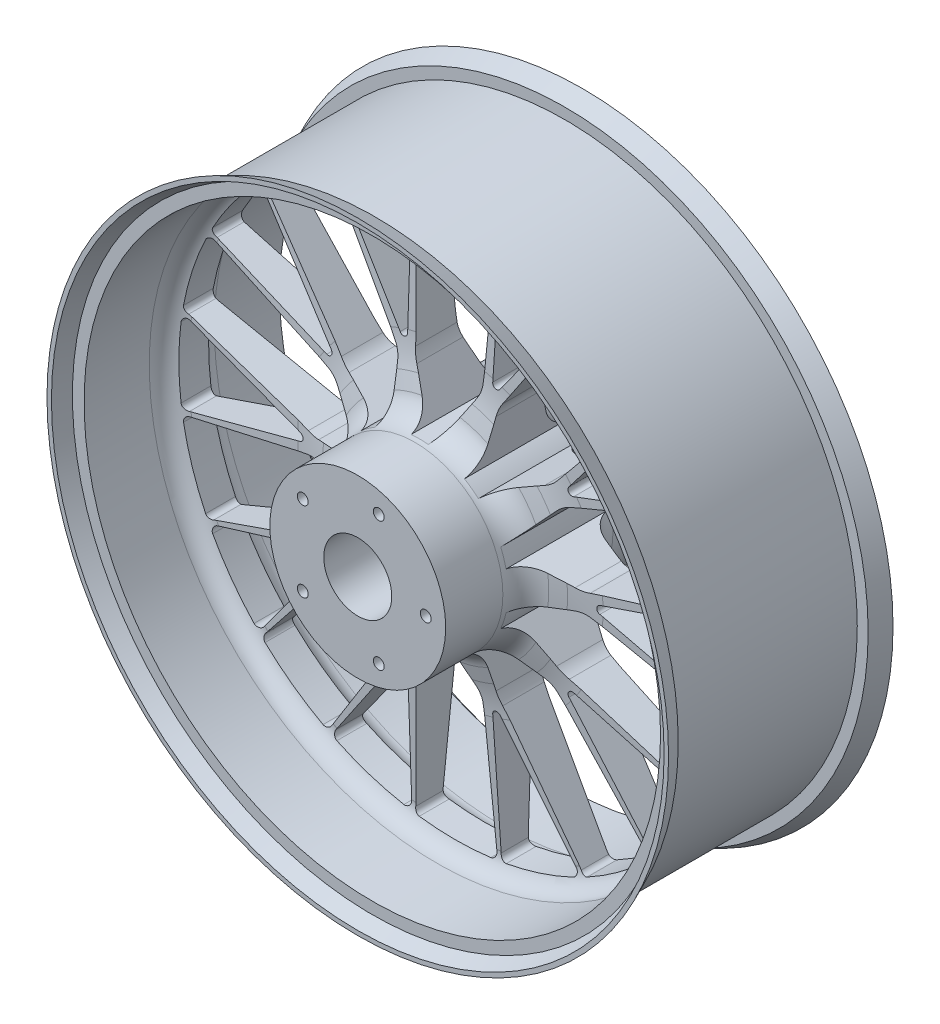
from build123d import *

# Parameters (mm, degrees)
SKETCH1_R           = 228.6
SKETCH1_R_2         = 25
SKETCH1_R_3         = 4
BOSS_EXTRUDE1_DEPTH = 82.55


with BuildPart() as part:
    # Sketch1 → Boss-Extrude1 (new body, symmetric)
    with BuildSketch(Plane.XY):
        Circle(SKETCH1_R)
        Circle(SKETCH1_R_2, mode=Mode.SUBTRACT)
        with Locations((15.45085, 47.552826)):
            Circle(SKETCH1_R_3, mode=Mode.SUBTRACT)
        with Locations((50, 0)):
            Circle(SKETCH1_R_3, mode=Mode.SUBTRACT)
        with Locations((15.45085, -47.552826)):
            Circle(SKETCH1_R_3, mode=Mode.SUBTRACT)
        with Locations((-40.45085, -29.389263)):
            Circle(SKETCH1_R_3, mode=Mode.SUBTRACT)
        with Locations((-40.45085, 29.389263)):
            Circle(SKETCH1_R_3, mode=Mode.SUBTRACT)
        with BuildLine():
            Line((-29.808072, 197.311036), (-24.75602, 100.912126))
            ThreePointArc((-24.75602, 100.912126), (-23.959824, 96.278538), (-22.103937, 91.958845))
            Line((-22.103937, 91.958845), (-6.35921, 64.688179))
            ThreePointArc((-6.35921, 64.688179), (0, 65), (6.35921, 64.688179))
            Line((6.35921, 64.688179), (22.103937, 91.958845))
            ThreePointArc((22.103937, 91.958845), (23.959824, 96.278538), (24.75602, 100.912126))
            Line((24.75602, 100.912126), (29.808072, 197.311036))
            ThreePointArc((29.808072, 197.311036), (28.887709, 200.079593), (26.331899, 201.486652))
            ThreePointArc((26.331899, 201.486652), (0, 203.2), (-26.331899, 201.486652))
            ThreePointArc((-26.331899, 201.486652), (-28.887709, 200.079593), (-29.808072, 197.311036))
        make_face(mode=Mode.SUBTRACT)
        with BuildLine():
            Line((91.86128, 177.148727), (39.286619, 96.190848))
            ThreePointArc((39.286619, 96.190848), (37.2072, 91.974204), (36.169592, 87.388636))
            Line((36.169592, 87.388636), (32.878048, 56.071686))
            ThreePointArc((32.878048, 56.071686), (38.206041, 52.586105), (43.167467, 48.595986))
            Line((43.167467, 48.595986), (71.934513, 61.4039))
            ThreePointArc((71.934513, 61.4039), (75.975009, 63.807742), (79.3427, 67.088401))
            Line((79.3427, 67.088401), (140.091754, 142.107236))
            ThreePointArc((140.091754, 142.107236), (140.974482, 144.888022), (139.733836, 147.528624))
            ThreePointArc((139.733836, 147.528624), (119.437963, 164.392253), (97.127929, 178.483628))
            ThreePointArc((97.127929, 178.483628), (94.233187, 178.84756), (91.86128, 177.148727))
        make_face(mode=Mode.SUBTRACT)
        with BuildLine():
            Line((-31.301343, 105.619631), (-32.875918, 195.826934))
            ThreePointArc((-32.875918, 195.826934), (-34.34903, 198.858401), (-37.615776, 199.68799))
            ThreePointArc((-37.615776, 199.68799), (-62.772389, 193.261137), (-86.904095, 183.678846))
            ThreePointArc((-86.904095, 183.678846), (-89.059737, 181.088459), (-88.471019, 177.770281))
            Line((-88.471019, 177.770281), (-36.758343, 103.846544))
            ThreePointArc((-36.758343, 103.846544), (-35.2528, 102.722302), (-33.373835, 102.714104))
            ThreePointArc((-33.373835, 102.714104), (-31.85854, 103.825164), (-31.301343, 105.619631))
        make_face(mode=Mode.SUBTRACT)
        with BuildLine():
            Line((36.758343, 103.846544), (88.507008, 177.751297))
            ThreePointArc((88.507008, 177.751297), (89.097086, 181.069679), (86.941853, 183.660976))
            ThreePointArc((86.941853, 183.660976), (62.812117, 193.248229), (37.656827, 199.680253))
            ThreePointArc((37.656827, 199.680253), (34.390285, 198.851641), (32.916192, 195.821138))
            Line((32.916192, 195.821138), (31.301343, 105.619631))
            ThreePointArc((31.301343, 105.619631), (31.85854, 103.825164), (33.373835, 102.714104))
            ThreePointArc((33.373835, 102.714104), (35.2528, 102.722302), (36.758343, 103.846544))
        make_face(mode=Mode.SUBTRACT)
        with BuildLine():
            Line((178.442745, 89.321625), (88.323104, 54.727936))
            ThreePointArc((88.323104, 54.727936), (84.162338, 52.538851), (80.627566, 49.438939))
            Line((80.627566, 49.438939), (59.55701, 26.037715))
            ThreePointArc((59.55701, 26.037715), (61.818674, 20.086105), (63.487218, 13.941778))
            Line((63.487218, 13.941778), (94.288551, 7.394753))
            ThreePointArc((94.288551, 7.394753), (98.970324, 6.964558), (103.623165, 7.639188))
            Line((103.623165, 7.639188), (196.865147, 32.623302))
            ThreePointArc((196.865147, 32.623302), (199.213794, 34.354151), (199.762198, 37.219676))
            ThreePointArc((199.762198, 37.219676), (193.254684, 62.792253), (183.48819, 87.305924))
            ThreePointArc((183.48819, 87.305924), (181.360208, 89.301838), (178.442745, 89.321625))
        make_face(mode=Mode.SUBTRACT)
        with BuildLine():
            Line((90.777591, 62.407607), (176.083264, 91.780706))
            ThreePointArc((176.083264, 91.780706), (178.511144, 94.118494), (178.29065, 97.481712))
            ThreePointArc((178.29065, 97.481712), (164.404529, 119.421065), (147.834121, 139.41059))
            ThreePointArc((147.834121, 139.41059), (144.704387, 140.660254), (141.730536, 139.074977))
            Line((141.730536, 139.074977), (87.40498, 67.049608))
            ThreePointArc((87.40498, 67.049608), (86.801001, 65.270343), (87.373835, 63.480807))
            ThreePointArc((87.373835, 63.480807), (88.898769, 62.383012), (90.777591, 62.407607))
        make_face(mode=Mode.SUBTRACT)
        with BuildLine():
            Line((196.865147, -32.623302), (103.623165, -7.639188))
            ThreePointArc((103.623165, -7.639188), (98.970324, -6.964558), (94.288551, -7.394753))
            Line((94.288551, -7.394753), (63.487218, -13.941778))
            ThreePointArc((63.487218, -13.941778), (61.818674, -20.086105), (59.55701, -26.037715))
            Line((59.55701, -26.037715), (80.627566, -49.438939))
            ThreePointArc((80.627566, -49.438939), (84.162338, -52.538851), (88.323104, -54.727936))
            Line((88.323104, -54.727936), (178.442745, -89.321625))
            ThreePointArc((178.442745, -89.321625), (181.360208, -89.301838), (183.48819, -87.305924))
            ThreePointArc((183.48819, -87.305924), (193.254684, -62.792253), (199.762198, -37.219676))
            ThreePointArc((199.762198, -37.219676), (199.213794, -34.354151), (196.865147, -32.623302))
        make_face(mode=Mode.SUBTRACT)
        with BuildLine():
            Line((110.122885, -2.868914), (196.401699, -29.246995))
            ThreePointArc((196.401699, -29.246995), (199.740012, -28.782757), (201.538478, -25.932253))
            ThreePointArc((201.538478, -25.932253), (203.199999, -0.020887), (201.543805, 25.890821))
            ThreePointArc((201.543805, 25.890821), (199.746331, 28.741432), (196.408632, 29.206901))
            Line((196.408632, 29.206901), (110.122885, 2.868914))
            ThreePointArc((110.122885, 2.868914), (108.588429, 1.784468), (108, 0))
            ThreePointArc((108, 0), (108.588429, -1.784468), (110.122885, -2.868914))
        make_face(mode=Mode.SUBTRACT)
        with BuildLine():
            Line((140.091754, -142.107236), (79.3427, -67.088401))
            ThreePointArc((79.3427, -67.088401), (75.975009, -63.807742), (71.934513, -61.4039))
            Line((71.934513, -61.4039), (43.167467, -48.595986))
            ThreePointArc((43.167467, -48.595986), (38.206041, -52.586105), (32.878048, -56.071686))
            Line((32.878048, -56.071686), (36.169592, -87.388636))
            ThreePointArc((36.169592, -87.388636), (37.2072, -91.974204), (39.286619, -96.190848))
            Line((39.286619, -96.190848), (91.86128, -177.148727))
            ThreePointArc((91.86128, -177.148727), (94.233187, -178.84756), (97.127929, -178.483628))
            ThreePointArc((97.127929, -178.483628), (119.437963, -164.392253), (139.733836, -147.528624))
            ThreePointArc((139.733836, -147.528624), (140.974482, -144.888022), (140.091754, -142.107236))
        make_face(mode=Mode.SUBTRACT)
        with BuildLine():
            Line((87.40498, -67.049608), (141.70136, -139.103338))
            ThreePointArc((141.70136, -139.103338), (144.674984, -140.689972), (147.805458, -139.440979))
            ThreePointArc((147.805458, -139.440979), (164.379976, -119.45486), (178.270606, -97.518362))
            ThreePointArc((178.270606, -97.518362), (178.491966, -94.155641), (176.065307, -91.817218))
            Line((176.065307, -91.817218), (90.777591, -62.407607))
            ThreePointArc((90.777591, -62.407607), (88.898769, -62.383012), (87.373835, -63.480807))
            ThreePointArc((87.373835, -63.480807), (86.801001, -65.270343), (87.40498, -67.049608))
        make_face(mode=Mode.SUBTRACT)
        with BuildLine():
            Line((29.808072, -197.311036), (24.75602, -100.912126))
            ThreePointArc((24.75602, -100.912126), (23.959824, -96.278538), (22.103937, -91.958845))
            Line((22.103937, -91.958845), (6.35921, -64.688179))
            ThreePointArc((6.35921, -64.688179), (0, -65), (-6.35921, -64.688179))
            Line((-6.35921, -64.688179), (-22.103937, -91.958845))
            ThreePointArc((-22.103937, -91.958845), (-23.959824, -96.278538), (-24.75602, -100.912126))
            Line((-24.75602, -100.912126), (-29.808072, -197.311036))
            ThreePointArc((-29.808072, -197.311036), (-28.887709, -200.079593), (-26.331899, -201.486652))
            ThreePointArc((-26.331899, -201.486652), (0, -203.2), (26.331899, -201.486652))
            ThreePointArc((26.331899, -201.486652), (28.887709, -200.079593), (29.808072, -197.311036))
        make_face(mode=Mode.SUBTRACT)
        with BuildLine():
            Line((31.301343, -105.619631), (32.875918, -195.826934))
            ThreePointArc((32.875918, -195.826934), (34.34903, -198.858401), (37.615776, -199.68799))
            ThreePointArc((37.615776, -199.68799), (62.772389, -193.261137), (86.904095, -183.678846))
            ThreePointArc((86.904095, -183.678846), (89.059737, -181.088459), (88.471019, -177.770281))
            Line((88.471019, -177.770281), (36.758343, -103.846544))
            ThreePointArc((36.758343, -103.846544), (35.2528, -102.722302), (33.373835, -102.714104))
            ThreePointArc((33.373835, -102.714104), (31.85854, -103.825164), (31.301343, -105.619631))
        make_face(mode=Mode.SUBTRACT)
        with BuildLine():
            Line((-91.86128, -177.148727), (-39.286619, -96.190848))
            ThreePointArc((-39.286619, -96.190848), (-37.2072, -91.974204), (-36.169592, -87.388636))
            Line((-36.169592, -87.388636), (-32.878048, -56.071686))
            ThreePointArc((-32.878048, -56.071686), (-38.206041, -52.586105), (-43.167467, -48.595986))
            Line((-43.167467, -48.595986), (-71.934513, -61.4039))
            ThreePointArc((-71.934513, -61.4039), (-75.975009, -63.807742), (-79.3427, -67.088401))
            Line((-79.3427, -67.088401), (-140.091754, -142.107236))
            ThreePointArc((-140.091754, -142.107236), (-140.974482, -144.888022), (-139.733836, -147.528624))
            ThreePointArc((-139.733836, -147.528624), (-119.437963, -164.392253), (-97.127929, -178.483628))
            ThreePointArc((-97.127929, -178.483628), (-94.233187, -178.84756), (-91.86128, -177.148727))
        make_face(mode=Mode.SUBTRACT)
        with BuildLine():
            Line((-36.758343, -103.846544), (-88.507008, -177.751297))
            ThreePointArc((-88.507008, -177.751297), (-89.097086, -181.069679), (-86.941853, -183.660976))
            ThreePointArc((-86.941853, -183.660976), (-62.812117, -193.248229), (-37.656827, -199.680253))
            ThreePointArc((-37.656827, -199.680253), (-34.390285, -198.851641), (-32.916192, -195.821138))
            Line((-32.916192, -195.821138), (-31.301343, -105.619631))
            ThreePointArc((-31.301343, -105.619631), (-31.85854, -103.825164), (-33.373835, -102.714104))
            ThreePointArc((-33.373835, -102.714104), (-35.2528, -102.722302), (-36.758343, -103.846544))
        make_face(mode=Mode.SUBTRACT)
        with BuildLine():
            Line((-178.442745, -89.321625), (-88.323104, -54.727936))
            ThreePointArc((-88.323104, -54.727936), (-84.162338, -52.538851), (-80.627566, -49.438939))
            Line((-80.627566, -49.438939), (-59.55701, -26.037715))
            ThreePointArc((-59.55701, -26.037715), (-61.818674, -20.086105), (-63.487218, -13.941778))
            Line((-63.487218, -13.941778), (-94.288551, -7.394753))
            ThreePointArc((-94.288551, -7.394753), (-98.970324, -6.964558), (-103.623165, -7.639188))
            Line((-103.623165, -7.639188), (-196.865147, -32.623302))
            ThreePointArc((-196.865147, -32.623302), (-199.213794, -34.354151), (-199.762198, -37.219676))
            ThreePointArc((-199.762198, -37.219676), (-193.254684, -62.792253), (-183.48819, -87.305924))
            ThreePointArc((-183.48819, -87.305924), (-181.360208, -89.301838), (-178.442745, -89.321625))
        make_face(mode=Mode.SUBTRACT)
        with BuildLine():
            Line((-90.777591, -62.407607), (-176.083264, -91.780706))
            ThreePointArc((-176.083264, -91.780706), (-178.511144, -94.118494), (-178.29065, -97.481712))
            ThreePointArc((-178.29065, -97.481712), (-164.404529, -119.421065), (-147.834121, -139.41059))
            ThreePointArc((-147.834121, -139.41059), (-144.704387, -140.660254), (-141.730536, -139.074977))
            Line((-141.730536, -139.074977), (-87.40498, -67.049608))
            ThreePointArc((-87.40498, -67.049608), (-86.801001, -65.270343), (-87.373835, -63.480807))
            ThreePointArc((-87.373835, -63.480807), (-88.898769, -62.383012), (-90.777591, -62.407607))
        make_face(mode=Mode.SUBTRACT)
        with BuildLine():
            Line((-196.865147, 32.623302), (-103.623165, 7.639188))
            ThreePointArc((-103.623165, 7.639188), (-98.970324, 6.964558), (-94.288551, 7.394753))
            Line((-94.288551, 7.394753), (-63.487218, 13.941778))
            ThreePointArc((-63.487218, 13.941778), (-61.818674, 20.086105), (-59.55701, 26.037715))
            Line((-59.55701, 26.037715), (-80.627566, 49.438939))
            ThreePointArc((-80.627566, 49.438939), (-84.162338, 52.538851), (-88.323104, 54.727936))
            Line((-88.323104, 54.727936), (-178.442745, 89.321625))
            ThreePointArc((-178.442745, 89.321625), (-181.360208, 89.301838), (-183.48819, 87.305924))
            ThreePointArc((-183.48819, 87.305924), (-193.254684, 62.792253), (-199.762198, 37.219676))
            ThreePointArc((-199.762198, 37.219676), (-199.213794, 34.354151), (-196.865147, 32.623302))
        make_face(mode=Mode.SUBTRACT)
        with BuildLine():
            Line((-110.122885, 2.868914), (-196.401699, 29.246995))
            ThreePointArc((-196.401699, 29.246995), (-199.740012, 28.782757), (-201.538478, 25.932253))
            ThreePointArc((-201.538478, 25.932253), (-203.199999, 0.020887), (-201.543805, -25.890821))
            ThreePointArc((-201.543805, -25.890821), (-199.746331, -28.741432), (-196.408632, -29.206901))
            Line((-196.408632, -29.206901), (-110.122885, -2.868914))
            ThreePointArc((-110.122885, -2.868914), (-108.588429, -1.784468), (-108, 0))
            ThreePointArc((-108, 0), (-108.588429, 1.784468), (-110.122885, 2.868914))
        make_face(mode=Mode.SUBTRACT)
        with BuildLine():
            Line((-140.091754, 142.107236), (-79.3427, 67.088401))
            ThreePointArc((-79.3427, 67.088401), (-75.975009, 63.807742), (-71.934513, 61.4039))
            Line((-71.934513, 61.4039), (-43.167467, 48.595986))
            ThreePointArc((-43.167467, 48.595986), (-38.206041, 52.586105), (-32.878048, 56.071686))
            Line((-32.878048, 56.071686), (-36.169592, 87.388636))
            ThreePointArc((-36.169592, 87.388636), (-37.2072, 91.974204), (-39.286619, 96.190848))
            Line((-39.286619, 96.190848), (-91.86128, 177.148727))
            ThreePointArc((-91.86128, 177.148727), (-94.233187, 178.84756), (-97.127929, 178.483628))
            ThreePointArc((-97.127929, 178.483628), (-119.437963, 164.392253), (-139.733836, 147.528624))
            ThreePointArc((-139.733836, 147.528624), (-140.974482, 144.888022), (-140.091754, 142.107236))
        make_face(mode=Mode.SUBTRACT)
        with BuildLine():
            Line((-87.40498, 67.049608), (-141.70136, 139.103338))
            ThreePointArc((-141.70136, 139.103338), (-144.674984, 140.689972), (-147.805458, 139.440979))
            ThreePointArc((-147.805458, 139.440979), (-164.379976, 119.45486), (-178.270606, 97.518362))
            ThreePointArc((-178.270606, 97.518362), (-178.491966, 94.155641), (-176.065307, 91.817218))
            Line((-176.065307, 91.817218), (-90.777591, 62.407607))
            ThreePointArc((-90.777591, 62.407607), (-88.898769, 62.383012), (-87.373835, 63.480807))
            ThreePointArc((-87.373835, 63.480807), (-86.801001, 65.270343), (-87.40498, 67.049608))
        make_face(mode=Mode.SUBTRACT)
    extrude(amount=BOSS_EXTRUDE1_DEPTH, both=True)

    # Sketch2 → Cut-Revolve1 (revolve, cut)
    with BuildSketch(Plane(origin=(0, 0, 0), x_dir=(0, 0, -1), z_dir=(1, 0, 0))):
        with BuildLine():
            Line((-10, 197.311036), (-14.45576, 112.290072))
            ThreePointArc((-14.45576, 112.290072), (-15.690153, 101.018907), (-18.192544, 89.959932))
            Line((-18.192544, 89.959932), (-21.28495, 79.175431))
            ThreePointArc((-21.28495, 79.175431), (-28.473883, 68.715468), (-40.510184, 64.688179))
            Line((-40.510184, 64.688179), (-82.55, 64.688179))
            Line((-82.55, 64.688179), (-82.55, 225.321297))
            Line((-82.55, 225.321297), (-71.85, 220.603187))
            Line((-71.85, 220.603187), (-71.85, 212))
            Line((-71.85, 212), (-23.939306, 212))
            ThreePointArc((-23.939306, 212), (-13.814215, 207.649917), (-10, 197.311036))
        make_face()
        Polygon((-82.55, 228.6), (82.55, 228.6), (69.85, 223), (69.85, 215), (-69.85, 215), (-69.85, 223), align=None)
        with BuildLine():
            Line((71.85, 220.603187), (71.85, 212))
            Line((71.85, 212), (23.939306, 212))
            ThreePointArc((23.939306, 212), (13.814215, 207.649917), (10, 197.311036))
            Line((10, 197.311036), (14.45576, 112.290072))
            ThreePointArc((14.45576, 112.290072), (15.690153, 101.018907), (18.192544, 89.959932))
            Line((18.192544, 89.959932), (21.28495, 79.175431))
            ThreePointArc((21.28495, 79.175431), (28.473883, 68.715468), (40.510184, 64.688179))
            Line((40.510184, 64.688179), (82.55, 64.688179))
            Line((82.55, 64.688179), (82.55, 225.321297))
            Line((82.55, 225.321297), (71.85, 220.603187))
        make_face()
    revolve(axis=Axis((0, 0, 0), (0, 0, -1)), mode=Mode.SUBTRACT)


solid = part.part
